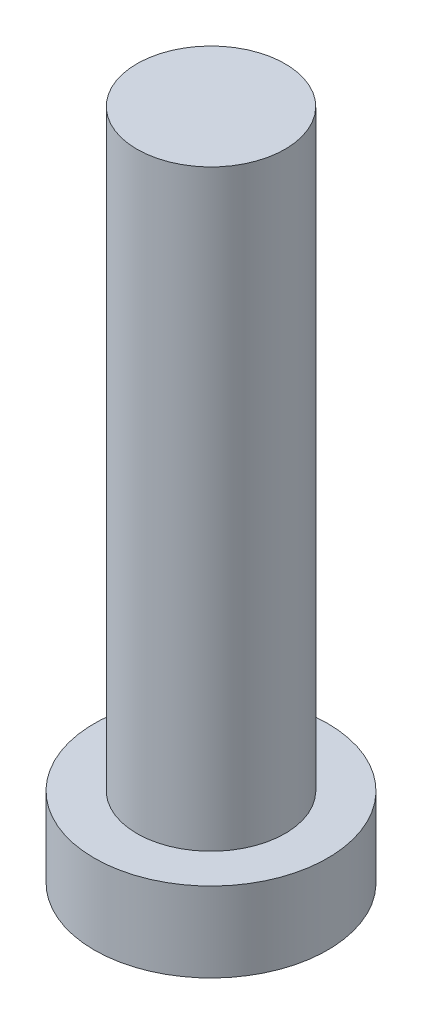
from build123d import *

# Parameters (mm, degrees)
SKETCH_1_R          = 3.15
EXTRUDE_1_DEPTH     = 2.15
SKETCH_2_R          = 2
EXTRUDE_2_DEPTH     = 16
CUT_EXTRUDE_1_DEPTH = 1.5


with BuildPart() as part:
    # 草图1 → 凸台-拉伸1 (new body)
    with BuildSketch(Plane(origin=(0, 0, 0), x_dir=(1, 0, 0), z_dir=(0, 1, 0))):
        Circle(SKETCH_1_R)
    extrude(amount=EXTRUDE_1_DEPTH)

    # 草图2 → 凸台-拉伸2 (add)
    with BuildSketch(Plane(origin=(0, 2.15, 0), x_dir=(1, 0, 0), z_dir=(0, 1, 0))):
        Circle(SKETCH_2_R)
    extrude(amount=EXTRUDE_2_DEPTH)

    # 草图3 → 切除-拉伸1 (cut)
    with BuildSketch(Plane.XZ):
        with BuildLine():
            Line((-0.5, 1), (-0.5, 2))
            Line((-0.5, 2), (0.5, 2))
            Line((0.5, 2), (0.5, 1))
            ThreePointArc((0.5, 1), (0.646446609, 0.646446609), (1, 0.5))
            Line((1, 0.5), (2, 0.5))
            Line((2, 0.5), (2, -0.5))
            Line((2, -0.5), (1, -0.5))
            ThreePointArc((1, -0.5), (0.646446609, -0.646446609), (0.5, -1))
            Line((0.5, -1), (0.5, -2))
            Line((0.5, -2), (-0.5, -2))
            Line((-0.5, -2), (-0.5, -1))
            ThreePointArc((-0.5, -1), (-0.646446609, -0.646446609), (-1, -0.5))
            Line((-1, -0.5), (-2, -0.5))
            Line((-2, -0.5), (-2, 0.5))
            Line((-2, 0.5), (-1, 0.5))
            ThreePointArc((-1, 0.5), (-0.646446609, 0.646446609), (-0.5, 1))
        make_face()
    extrude(amount=-CUT_EXTRUDE_1_DEPTH, mode=Mode.SUBTRACT)


solid = part.part
